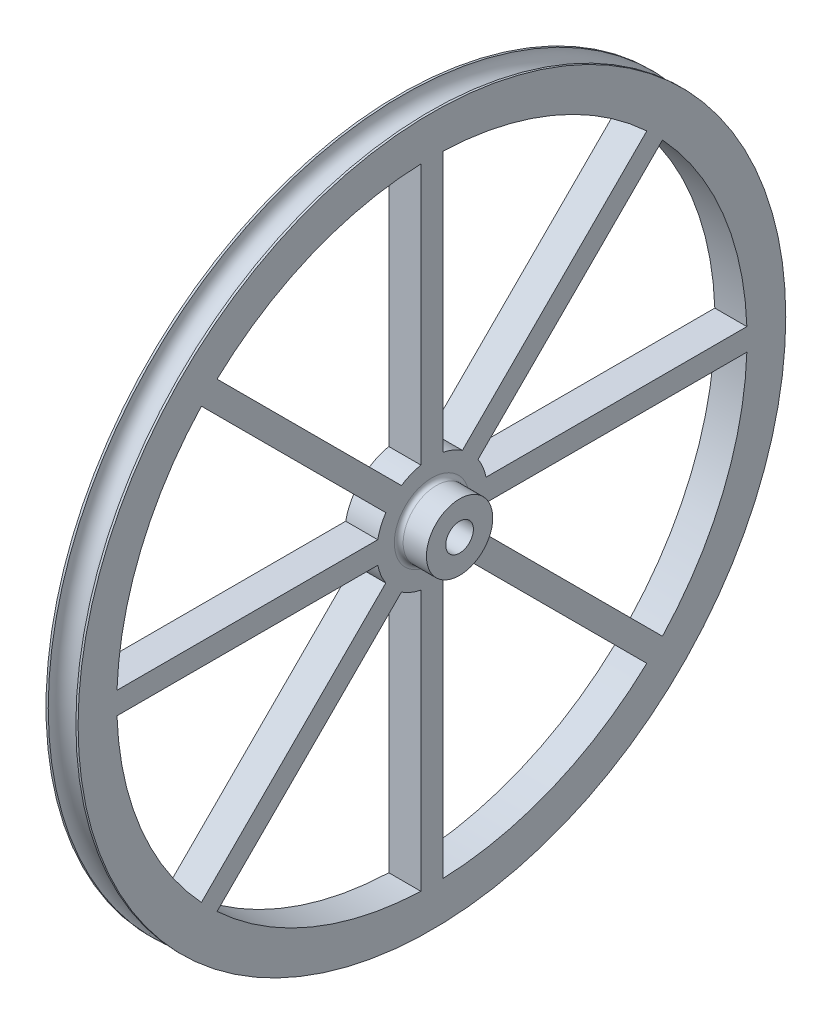
from build123d import *

# Parameters (mm, degrees)
SKETCH1_R           = 40.64
BOSS_EXTRUDE1_DEPTH = 3.683
SKETCH10_R          = 1.5875
CUT_EXTRUDE3_DEPTH  = 4.683
SKETCH12_R          = 1.5875
CUT_EXTRUDE4_DEPTH  = 4.683
SKETCH13_R          = 3.81
SKETCH13_R_2        = 1.5875
BOSS_EXTRUDE2_DEPTH = 3.175
FILLET1_R           = 0.508


with BuildPart() as part:
    # Sketch1 → Boss-Extrude1 (new body)
    with BuildSketch(Plane(origin=(0, 0, 0), x_dir=(0, 0, -1), z_dir=(1, 0, 0))):
        Circle(SKETCH1_R)
    extrude(amount=BOSS_EXTRUDE1_DEPTH)

    # Sketch10 → Cut-Revolve1 (revolve, cut)
    with BuildSketch(Plane.XY):
        with Locations((1.8415, 40.64)):
            Circle(SKETCH10_R)
    revolve(axis=Axis((-1.01619145, 0, 0), (1, 0, 0)), mode=Mode.SUBTRACT)

    # Sketch11 → Cut-Extrude3 (cut, through all)
    with BuildSketch(Plane(origin=(3.683, 0, 0), x_dir=(0, 0, -1), z_dir=(1, 0, 0))):
        with BuildLine():
            Line((-1.27, 36.172712436), (-1.27, 6.221703947))
            ThreePointArc((-1.27, 6.221703947), (-2.430039796, 5.866635031), (-3.501383439, 5.297434663))
            Line((-3.501383439, 5.297434663), (-24.679944646, 26.47599587))
            ThreePointArc((-24.679944646, 26.47599587), (-13.851226834, 33.439819679), (-1.27, 36.172712436))
        make_face()
        with BuildLine():
            Line((1.27, 36.172712436), (1.27, 6.221703947))
            ThreePointArc((1.27, 6.221703947), (2.430039796, 5.866635031), (3.501383439, 5.297434663))
            Line((3.501383439, 5.297434663), (24.679944646, 26.47599587))
            ThreePointArc((24.679944646, 26.47599587), (13.851226834, 33.439819679), (1.27, 36.172712436))
        make_face()
        with BuildLine():
            Line((26.47599587, 24.679944646), (5.297434663, 3.501383439))
            ThreePointArc((5.297434663, 3.501383439), (5.866635031, 2.430039796), (6.221703947, 1.27))
            Line((6.221703947, 1.27), (36.172712436, 1.27))
            ThreePointArc((36.172712436, 1.27), (33.439819679, 13.851226834), (26.47599587, 24.679944646))
        make_face()
        with BuildLine():
            Line((36.172712436, -1.27), (6.221703947, -1.27))
            ThreePointArc((6.221703947, -1.27), (5.866635031, -2.430039796), (5.297434663, -3.501383439))
            Line((5.297434663, -3.501383439), (26.47599587, -24.679944646))
            ThreePointArc((26.47599587, -24.679944646), (33.439819679, -13.851226834), (36.172712436, -1.27))
        make_face()
        with BuildLine():
            Line((24.679944646, -26.47599587), (3.501383439, -5.297434663))
            ThreePointArc((3.501383439, -5.297434663), (2.430039796, -5.866635031), (1.27, -6.221703947))
            Line((1.27, -6.221703947), (1.27, -36.172712436))
            ThreePointArc((1.27, -36.172712436), (13.851226834, -33.439819679), (24.679944646, -26.47599587))
        make_face()
        with BuildLine():
            Line((-1.27, -36.172712436), (-1.27, -6.221703947))
            ThreePointArc((-1.27, -6.221703947), (-2.430039796, -5.866635031), (-3.501383439, -5.297434663))
            Line((-3.501383439, -5.297434663), (-24.679944646, -26.47599587))
            ThreePointArc((-24.679944646, -26.47599587), (-13.851226834, -33.439819679), (-1.27, -36.172712436))
        make_face()
        with BuildLine():
            Line((-26.47599587, -24.679944646), (-5.297434663, -3.501383439))
            ThreePointArc((-5.297434663, -3.501383439), (-5.866635031, -2.430039796), (-6.221703947, -1.27))
            Line((-6.221703947, -1.27), (-36.172712436, -1.27))
            ThreePointArc((-36.172712436, -1.27), (-33.439819679, -13.851226834), (-26.47599587, -24.679944646))
        make_face()
        with BuildLine():
            Line((-36.172712436, 1.27), (-6.221703947, 1.27))
            ThreePointArc((-6.221703947, 1.27), (-5.866635031, 2.430039796), (-5.297434663, 3.501383439))
            Line((-5.297434663, 3.501383439), (-26.47599587, 24.679944646))
            ThreePointArc((-26.47599587, 24.679944646), (-33.439819679, 13.851226834), (-36.172712436, 1.27))
        make_face()
    extrude(amount=-CUT_EXTRUDE3_DEPTH, mode=Mode.SUBTRACT)

    # Sketch12 → Cut-Extrude4 (cut, through all)
    with BuildSketch(Plane(origin=(3.683, 0, 0), x_dir=(0, 0, -1), z_dir=(1, 0, 0))):
        Circle(SKETCH12_R)
    extrude(amount=-CUT_EXTRUDE4_DEPTH, mode=Mode.SUBTRACT)

    # Sketch13 → Boss-Extrude2 (add)
    with BuildSketch(Plane(origin=(3.683, 0, 0), x_dir=(0, 0, -1), z_dir=(1, 0, 0))):
        Circle(SKETCH13_R)
        Circle(SKETCH13_R_2, mode=Mode.SUBTRACT)
    extrude(amount=BOSS_EXTRUDE2_DEPTH)

    # Fillet1
    fillet1_edges = [part.edges().sort_by_distance(p)[0] for p in [
        (3.683, 0, 3.81),
    ]]
    fillet(fillet1_edges, radius=FILLET1_R)


solid = part.part
